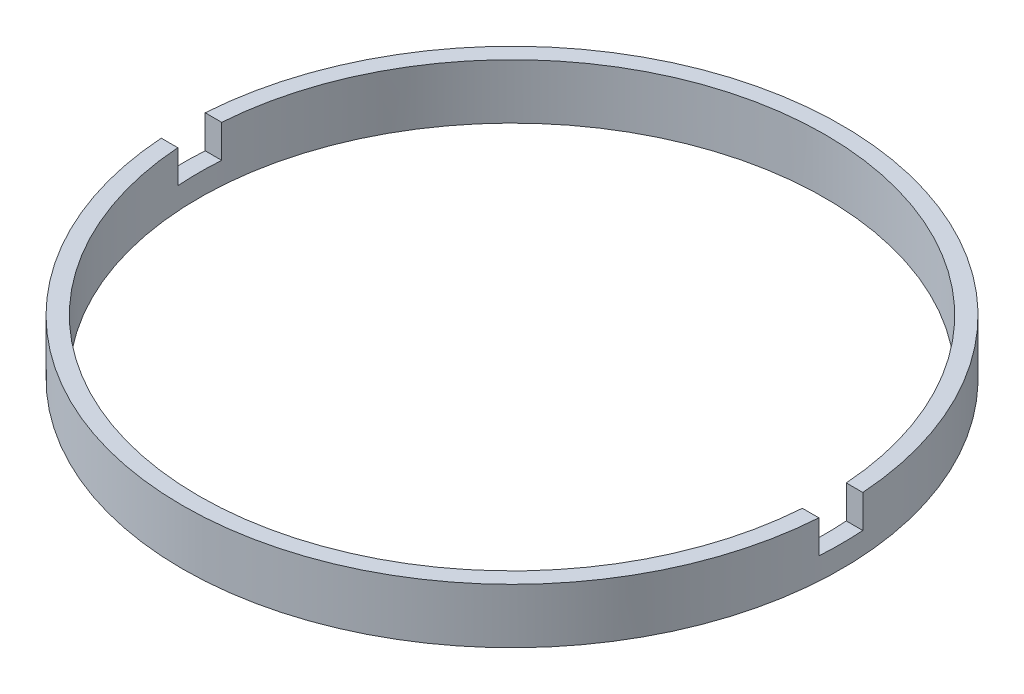
from build123d import *

# Parameters (mm, degrees)
SKETCH_1_W          = 0.75
SKETCH_1_H          = 2.5
SKETCH_2_W          = 53.705080546
SKETCH_2_H          = 2
CUT_EXTRUDE_1_DEPTH = 1.5


with BuildPart() as part:
    # 草图1 → 旋转1 (revolve)
    with BuildSketch(Plane.XY, mode=Mode.PRIVATE) as revolve_1_sk:
        with Locations((14.625, -3.214249787)):
            Rectangle(SKETCH_1_W, SKETCH_1_H)
    revolve(revolve_1_sk.sketch.rotate(Axis((0, 56.260842627, 0), (0, -1, 0)), 90), axis=Axis((0, 56.260842627, 0), (0, -1, 0)))  # turned: the seam where the file's is

    # 草图2 → 切除-拉伸1 (cut)
    with BuildSketch(Plane(origin=(0, -1.964249787, 0), x_dir=(1, 0, 0), z_dir=(0, 1, 0))):
        Rectangle(SKETCH_2_W, SKETCH_2_H)
    extrude(amount=-CUT_EXTRUDE_1_DEPTH, mode=Mode.SUBTRACT)


solid = part.part
